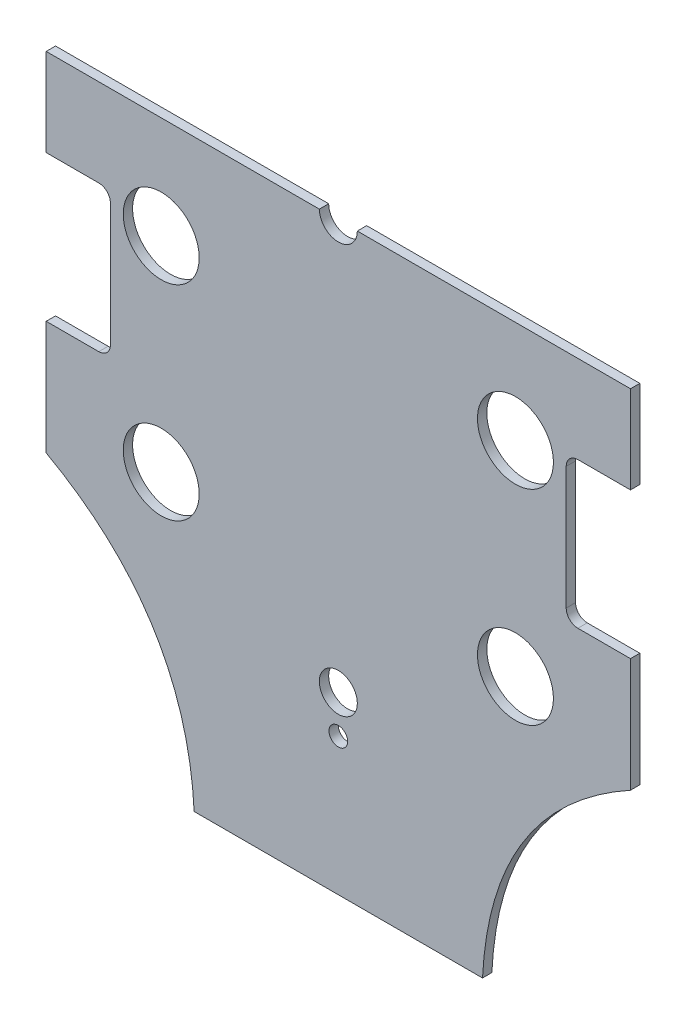
from build123d import *

# Parameters (mm, degrees)
SKETCH_1_R      = 3.25
SKETCH_1_R_2    = 6.5
SKETCH_1_R_3    = 1.6
EXTRUDE_2_DEPTH = 1.6


with BuildPart() as part:
    # 草图1 → 凸台-拉伸2 (new body)
    with BuildSketch(Plane.XY):
        with BuildLine():
            Line((-50, 20), (-41, 20))
            ThreePointArc((-41, 20), (-39.585786438, 19.414213562), (-39, 18))
            Line((-39, 18), (-39, -3))
            ThreePointArc((-39, -3), (-39.585786438, -4.414213562), (-41, -5))
            Line((-41, -5), (-50, -5))
            Line((-50, -5), (-50, -24.506949679))
            add(Edge.make_bspline(
                [(-50, -24.506949679), (-26.057041225, -37.751626241), (-24.673757374, -65)],
                knots=[0, 0, 0, 1, 1, 1], degree=2))
            Line((-24.673757374, -65), (24.673757374, -65))
            add(Edge.make_bspline(
                [(50, -24.506949679), (26.057041225, -37.751626241), (24.673757374, -65)],
                knots=[0, 0, 0, 1, 1, 1], degree=2))
            Line((50, -24.506949679), (50, -5))
            Line((50, -5), (41, -5))
            ThreePointArc((41, -5), (39.585786438, -4.414213562), (39, -3))
            Line((39, -3), (39, 18))
            ThreePointArc((39, 18), (39.585786438, 19.414213562), (41, 20))
            Line((41, 20), (50, 20))
            Line((50, 20), (50, 35))
            Line((50, 35), (3.25, 35))
            ThreePointArc((3.25, 35), (0, 31.75), (-3.25, 35))
            Line((-3.25, 35), (-50, 35))
            Line((-50, 35), (-50, 20))
        make_face()
        with Locations((0, -35)):
            Circle(SKETCH_1_R, mode=Mode.SUBTRACT)
        with Locations((30.310889132, -17.5)):
            Circle(SKETCH_1_R_2, mode=Mode.SUBTRACT)
        with Locations((30.310889132, 17.5)):
            Circle(SKETCH_1_R_2, mode=Mode.SUBTRACT)
        with Locations((-30.310889132, 17.5)):
            Circle(SKETCH_1_R_2, mode=Mode.SUBTRACT)
        with Locations((-30.310889132, -17.5)):
            Circle(SKETCH_1_R_2, mode=Mode.SUBTRACT)
        with Locations((0, -41.5)):
            Circle(SKETCH_1_R_3, mode=Mode.SUBTRACT)
    extrude(amount=EXTRUDE_2_DEPTH)


solid = part.part
